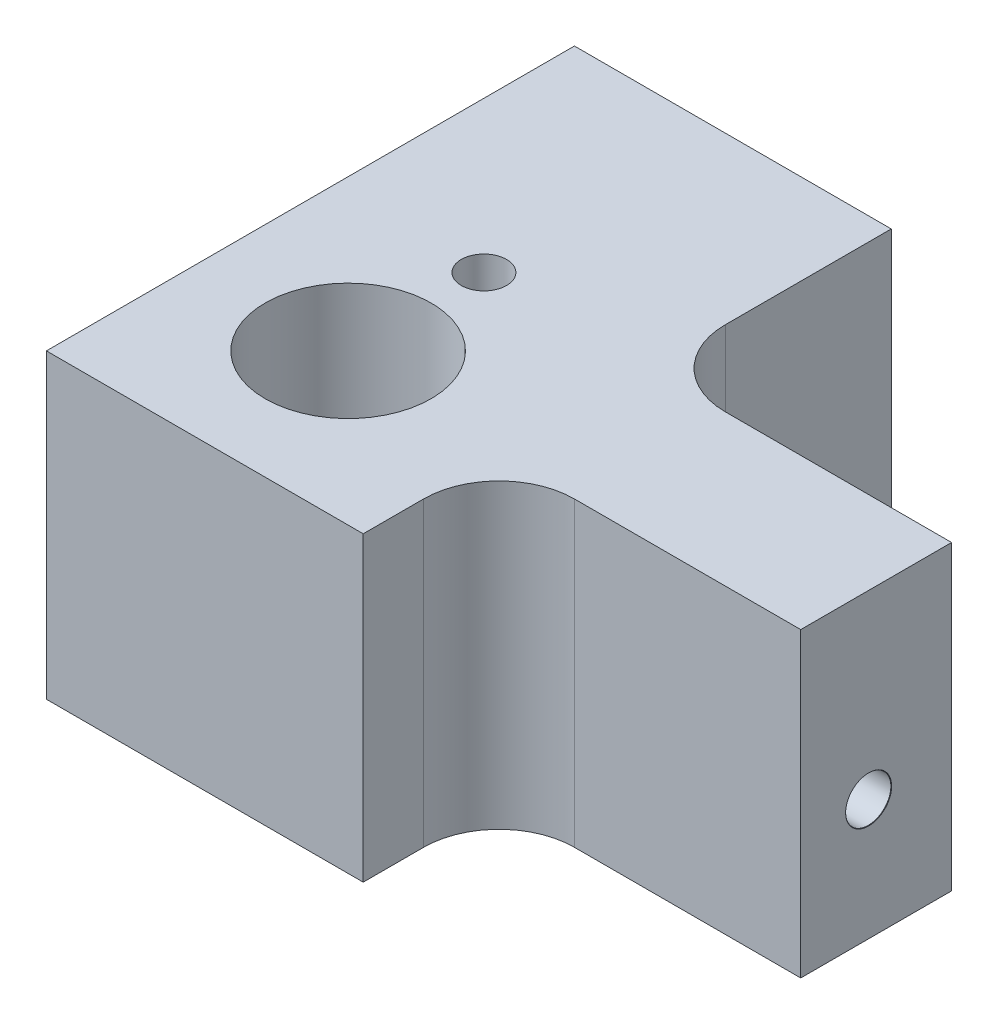
from build123d import *

# Parameters (mm, degrees)
SKETCH1_W                       = 49
SKETCH1_H                       = 35
BOSS_EXTRUDE1_DEPTH             = 20
F_3_0MM_DOWEL_HOLE1_D           = 3
F_3_0MM_DOWEL_HOLE1_DEPTH       = 11.098709071
F_3_0MM_DOWEL_HOLE1_CSINK_D     = 3.05
F_3_0MM_DOWEL_HOLE1_CSINK_ANGLE = 90
F_3_0MM_DOWEL_HOLE1_TIP         = 0.901290929
F_3_0MM_DOWEL_HOLE2_D           = 3
F_3_0MM_DOWEL_HOLE2_DEPTH       = 12
F_3_0MM_DOWEL_HOLE2_CSINK_D     = 3.05
F_3_0MM_DOWEL_HOLE2_CSINK_ANGLE = 90
F_3_0MM_DOWEL_HOLE2_TIP         = 0.901290929
F_3_0MM_DOWEL_HOLE3_D           = 3
F_3_0MM_DOWEL_HOLE3_CSINK_D     = 3.05
F_3_0MM_DOWEL_HOLE3_CSINK_ANGLE = 90
SKETCH14_W                      = 8
SKETCH14_H                      = 35
SKETCH14_W_2                    = 20
SKETCH14_H_2                    = 16
SKETCH14_H_3                    = 9
CUT_EXTRUDE3_DEPTH              = 28
SKETCH15_R                      = 5.5
CUT_EXTRUDE4_DEPTH              = 30
FILLET1_R                       = 5


with BuildPart() as part:
    # Sketch1 → Boss-Extrude1 (new body)
    with BuildSketch(Plane(origin=(0, 0, 0), x_dir=(1, 0, 0), z_dir=(0, 1, 0))):
        with Locations((13.974428044, 4.809594096)):
            Rectangle(SKETCH1_W, SKETCH1_H)
    extrude(amount=BOSS_EXTRUDE1_DEPTH)

    # Ø3.0mm Dowel Hole1
    with Locations(Plane(origin=(0, 0, -22.309594096), x_dir=(-1, 0, 0), z_dir=(0, 0, -1))):
        with Locations((-7.474428044, 4)):
            CounterSinkHole(F_3_0MM_DOWEL_HOLE1_D / 2, F_3_0MM_DOWEL_HOLE1_CSINK_D / 2, depth=F_3_0MM_DOWEL_HOLE1_DEPTH, counter_sink_angle=F_3_0MM_DOWEL_HOLE1_CSINK_ANGLE)
            with Locations((0, 0, -(F_3_0MM_DOWEL_HOLE1_DEPTH + F_3_0MM_DOWEL_HOLE1_TIP / 2))):  # 118° drill point
                Cone(0, F_3_0MM_DOWEL_HOLE1_D / 2, F_3_0MM_DOWEL_HOLE1_TIP, mode=Mode.SUBTRACT)

    # Ø3.0mm Dowel Hole2
    with Locations(Plane(origin=(38.474428044, 0, 0), x_dir=(0, 0, -1), z_dir=(1, 0, 0))):
        with Locations((0.809594096, 8)):
            CounterSinkHole(F_3_0MM_DOWEL_HOLE2_D / 2, F_3_0MM_DOWEL_HOLE2_CSINK_D / 2, depth=F_3_0MM_DOWEL_HOLE2_DEPTH, counter_sink_angle=F_3_0MM_DOWEL_HOLE2_CSINK_ANGLE)
            with Locations((0, 0, -(F_3_0MM_DOWEL_HOLE2_DEPTH + F_3_0MM_DOWEL_HOLE2_TIP / 2))):  # 118° drill point
                Cone(0, F_3_0MM_DOWEL_HOLE2_D / 2, F_3_0MM_DOWEL_HOLE2_TIP, mode=Mode.SUBTRACT)

    # Ø3.0mm Dowel Hole3 (through all)
    with Locations(Plane(origin=(0, 0, 0), x_dir=(-1, 0, 0), z_dir=(0, -1, 0))):
        with Locations((-7.474428044, 6.309594096)):
            CounterSinkHole(F_3_0MM_DOWEL_HOLE3_D / 2, F_3_0MM_DOWEL_HOLE3_CSINK_D / 2, counter_sink_angle=F_3_0MM_DOWEL_HOLE3_CSINK_ANGLE)

    # Sketch14 → Cut-Extrude3 (cut)
    with BuildSketch(Plane(origin=(0, 20, 0), x_dir=(1, 0, 0), z_dir=(0, 1, 0))):
        with Locations((-6.525571956, 4.809594096)):
            Rectangle(SKETCH14_W, SKETCH14_H)
        with Locations((28.474428044, 14.309594096)):
            Rectangle(SKETCH14_W_2, SKETCH14_H_2)
        with Locations((28.474428044, -8.190405904)):
            Rectangle(SKETCH14_W_2, SKETCH14_H_3)
    extrude(amount=-CUT_EXTRUDE3_DEPTH, mode=Mode.SUBTRACT)

    # Sketch15 → Cut-Extrude4 (cut)
    with BuildSketch(Plane(origin=(0, 20, 0), x_dir=(1, 0, 0), z_dir=(0, 1, 0))):
        with Locations((7.474428044, -2.690405904)):
            Circle(SKETCH15_R)
    extrude(amount=-CUT_EXTRUDE4_DEPTH, mode=Mode.SUBTRACT)

    # Fillet1
    fillet1_edges = [part.edges().sort_by_distance(p)[0] for p in [
        (18.474428044, 10, -6.309594096),
        (18.474428044, 10, 3.690405904),
    ]]
    fillet(fillet1_edges, radius=FILLET1_R)


solid = part.part
